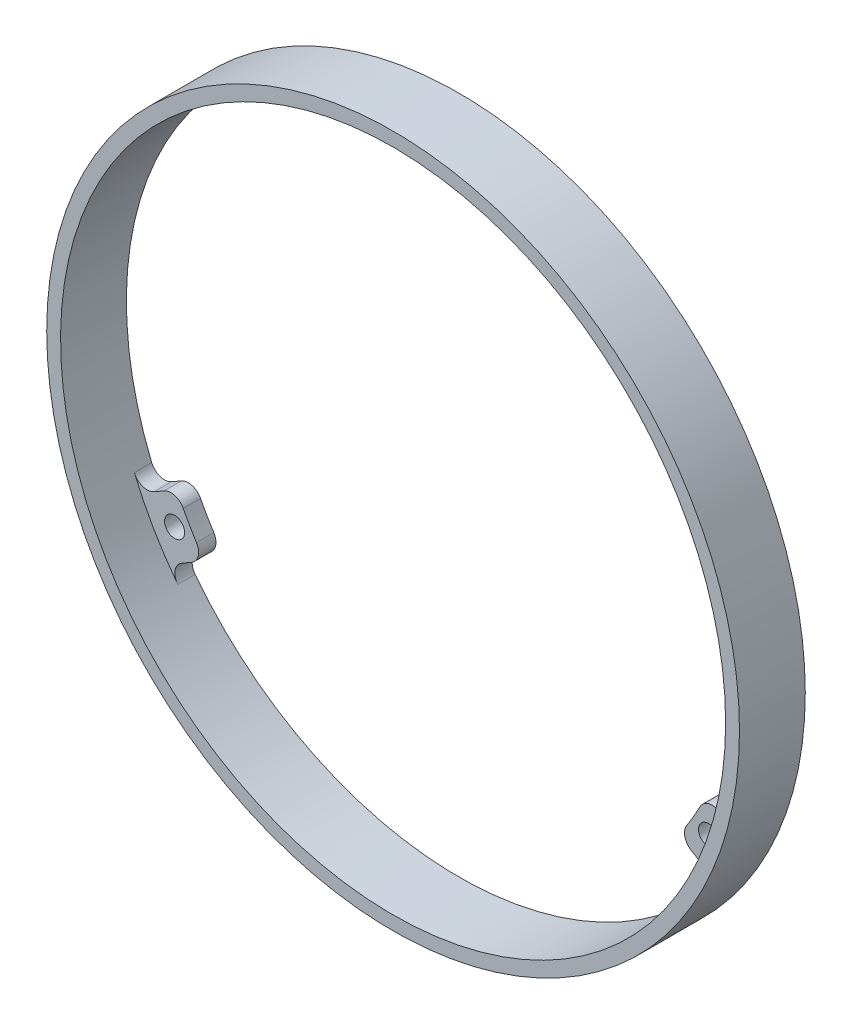
from build123d import *

# Parameters (mm, degrees)
SKETCH1_R                = 50
SKETCH1_R_2              = 48
EXTRUDE1_DEPTH           = 9.5
EXTRUDE2_DEPTH           = 2.5
SKETCH3_R                = 1.45
EXTRUDE3_DEPTH           = 2.5
FILLET1_R                = 2
CIRPATTERN1_COUNT        = 3
FILLET1_OF_CIRPATTERN1_R = 2


with BuildPart() as part:
    # Sketch1 → Extrude1 (new body)
    with BuildSketch(Plane.XY):
        Circle(SKETCH1_R)
        Circle(SKETCH1_R_2, mode=Mode.SUBTRACT)
    extrude(amount=EXTRUDE1_DEPTH)

    # Sketch2 → Extrude2 (add)
    with BuildSketch(Plane.XY):
        with BuildLine():
            Line((-4, 47.833042972), (-4, 41.809089921))
            ThreePointArc((-4, 41.809089921), (0, 42), (4, 41.809089921))
            Line((4, 41.809089921), (4, 47.833042972))
            ThreePointArc((4, 47.833042972), (0, 48), (-4, 47.833042972))
        make_face()
    extrude2 = extrude(amount=EXTRUDE2_DEPTH)

    # Sketch3 → Extrude3 (cut)
    with BuildSketch(Plane.XY.offset(2.5)):
        with Locations((0, 44.5)):
            Circle(SKETCH3_R)
    extrude3 = extrude(amount=-EXTRUDE3_DEPTH, mode=Mode.SUBTRACT)

    # Fillet1
    fillet1_edges = [part.edges().sort_by_distance(p)[0] for p in [
        (4, 47.833042972, 1.25),
        (-4, 47.833042972, 1.25),
        (-4, 41.809089921, 1.25),
        (4, 41.809089921, 1.25),
    ]]
    fillet(fillet1_edges, radius=FILLET1_R)

    # CirPattern1: Extrude2, Extrude3 ×3 about axis
    cirpattern1_axis = Axis((0, 0, 0), (0, 0, 1))
    for i in range(1, CIRPATTERN1_COUNT):
        add(extrude2.rotate(cirpattern1_axis, i * 360 / CIRPATTERN1_COUNT))
        add(extrude3.rotate(cirpattern1_axis, i * 360 / CIRPATTERN1_COUNT), mode=Mode.SUBTRACT)

    # Fillet1 of CirPattern1
    fillet1_of_cirpattern1_edges = [part.edges().sort_by_distance(p)[0] for p in [
        (-43.424630354, -20.452419871, 1.25),
        (-39.424630354, -27.380623101, 1.25),
        (-34.20773398, -24.368646576, 1.25),
        (-38.20773398, -17.440443345, 1.25),
        (39.424630354, -27.380623101, 1.25),
        (43.424630354, -20.452419871, 1.25),
        (38.20773398, -17.440443345, 1.25),
        (34.20773398, -24.368646576, 1.25),
    ]]
    fillet(fillet1_of_cirpattern1_edges, radius=FILLET1_OF_CIRPATTERN1_R)


solid = part.part
